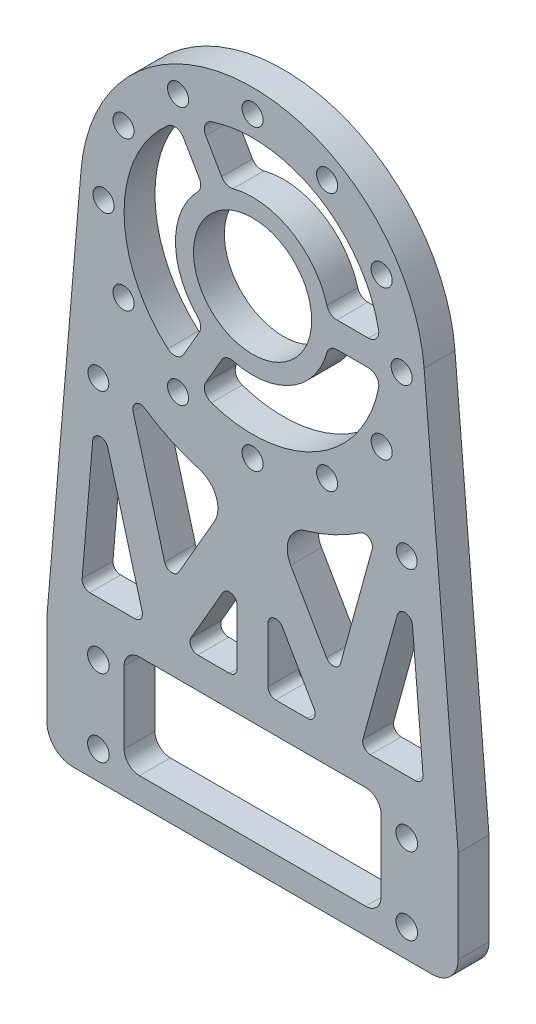
from build123d import *

# Parameters (mm, degrees)
SKETCH_1_R          = 33.5
SKETCH_1_R_2        = 25
SKETCH_1_W          = 80
SKETCH_1_H          = 20
SKETCH_1_R_3        = 2.1
EXTRUDE_1_DEPTH     = 6
SKETCH_3_R          = 2.05
CUT_EXTRUDE_1_DEPTH = 7
EXTRUDE_2_DEPTH     = 6
FILLET_1_R          = 2
SKETCH_5_W          = 80
SKETCH_5_H          = 3
EXTRUDE_3_DEPTH     = 6
FILLET_2_R          = 5
SKETCH_6_W          = 50
SKETCH_6_H          = 20
CUT_EXTRUDE_2_DEPTH = 10
FILLET_3_R          = 3
FILLET_4_R          = 1.5
FILLET_5_R          = 5
SKETCH_7_R          = 2.025
CUT_EXTRUDE_3_DEPTH = 10


with BuildPart() as part:
    # 草图1 → 凸台-拉伸1 (new body)
    with BuildSketch(Plane.XY):
        with Locations((0, 85.5)):
            Circle(SKETCH_1_R)
        with Locations((0, 85.5)):
            Circle(SKETCH_1_R_2, mode=Mode.SUBTRACT)
        with BuildLine():
            Line((-33.38100662, 88.32106311), (-40, 10))
            Line((-40, 10), (40, 10))
            Line((40, 10), (33.38100662, 88.32106311))
            ThreePointArc((33.38100662, 88.32106311), (33.470238435, 86.911785792), (33.5, 85.5))
            ThreePointArc((33.5, 85.5), (-1.411785792, 52.029761565), (-33.38100662, 88.32106311))
        make_face()
        Rectangle(SKETCH_1_W, SKETCH_1_H)
        with Locations((-30, 7.5)):
            Circle(SKETCH_1_R_3, mode=Mode.SUBTRACT)
        with Locations((30, 7.5)):
            Circle(SKETCH_1_R_3, mode=Mode.SUBTRACT)
        with Locations((30, -7.5)):
            Circle(SKETCH_1_R_3, mode=Mode.SUBTRACT)
        with Locations((-30, -7.5)):
            Circle(SKETCH_1_R_3, mode=Mode.SUBTRACT)
    extrude(amount=EXTRUDE_1_DEPTH)

    # 草图3 → 切除-拉伸1 (cut, through all)
    with BuildSketch(Plane.XY.offset(6)):
        with Locations((0, 114.5)):
            Circle(SKETCH_3_R)
        with Locations((14.5, 110.61473671)):
            Circle(SKETCH_3_R)
        with Locations((25.11473671, 100)):
            Circle(SKETCH_3_R)
        with Locations((29, 85.5)):
            Circle(SKETCH_3_R)
        with Locations((25.11473671, 71)):
            Circle(SKETCH_3_R)
        with Locations((14.5, 60.38526329)):
            Circle(SKETCH_3_R)
        with Locations((0, 56.5)):
            Circle(SKETCH_3_R)
        with Locations((-14.5, 60.38526329)):
            Circle(SKETCH_3_R)
        with Locations((-25.11473671, 71)):
            Circle(SKETCH_3_R)
        with Locations((-29, 85.5)):
            Circle(SKETCH_3_R)
        with Locations((-25.11473671, 100)):
            Circle(SKETCH_3_R)
        with Locations((-14.5, 110.61473671)):
            Circle(SKETCH_3_R)
    extrude(amount=-CUT_EXTRUDE_1_DEPTH, mode=Mode.SUBTRACT)


with BuildPart() as body_2:
    # 草图4 → 凸台-拉伸2 (new body)
    with BuildSketch(Plane.XY.offset(6)):
        with BuildLine():
            ThreePointArc((-10.272279454, 108.292109925), (-12.5, 107.150635095), (-14.602406473, 105.792109925))
            Line((-14.602406473, 105.792109925), (-9.560163238, 97.058688457))
            Line((-9.560163238, 97.058688457), (-7.77754959, 93.971111048))
            ThreePointArc((-7.77754959, 93.971111048), (-5.75, 95.459292144), (-3.447422571, 96.471111048))
            Line((-3.447422571, 96.471111048), (-5.230036219, 99.558688457))
            Line((-5.230036219, 99.558688457), (-10.272279454, 108.292109925))
        make_face()
        with BuildLine():
            ThreePointArc((25, 85.5), (24.968651828, 86.751569376), (24.874685928, 88))
            Line((24.874685928, 88), (14.790199458, 88))
            Line((14.790199458, 88), (11.22497216, 88))
            ThreePointArc((11.22497216, 88), (11.431036258, 86.757541283), (11.5, 85.5))
            ThreePointArc((11.5, 85.5), (11.431036258, 84.242458717), (11.22497216, 83))
            Line((11.22497216, 83), (14.790199458, 83))
            Line((14.790199458, 83), (24.874685928, 83))
            ThreePointArc((24.874685928, 83), (24.968651828, 84.248430624), (25, 85.5))
        make_face()
        with BuildLine():
            Line((-9.560163238, 73.941311543), (-14.602406473, 65.207890075))
            ThreePointArc((-14.602406473, 65.207890075), (-12.5, 63.849364905), (-10.272279454, 62.707890075))
            Line((-10.272279454, 62.707890075), (-5.230036219, 71.441311543))
            Line((-5.230036219, 71.441311543), (-3.447422571, 74.528888952))
            ThreePointArc((-3.447422571, 74.528888952), (-5.75, 75.540707856), (-7.77754959, 77.028888952))
            Line((-7.77754959, 77.028888952), (-9.560163238, 73.941311543))
        make_face()
        with BuildLine():
            Line((-7.77754959, 93.971111048), (-9.560163238, 97.058688457))
            ThreePointArc((-9.560163238, 97.058688457), (-15, 85.5), (-9.560163238, 73.941311543))
            Line((-9.560163238, 73.941311543), (-7.77754959, 77.028888952))
            ThreePointArc((-7.77754959, 77.028888952), (-11.5, 85.5), (-7.77754959, 93.971111048))
        make_face()
        with BuildLine():
            Line((-3.447422571, 74.528888952), (-5.230036219, 71.441311543))
            ThreePointArc((-5.230036219, 71.441311543), (7.5, 72.509618943), (14.790199458, 83))
            Line((14.790199458, 83), (11.22497216, 83))
            ThreePointArc((11.22497216, 83), (5.75, 75.540707856), (-3.447422571, 74.528888952))
        make_face()
        with BuildLine():
            ThreePointArc((14.790199458, 88), (7.5, 98.490381057), (-5.230036219, 99.558688457))
            Line((-5.230036219, 99.558688457), (-3.447422571, 96.471111048))
            ThreePointArc((-3.447422571, 96.471111048), (5.75, 95.459292144), (11.22497216, 88))
            Line((11.22497216, 88), (14.790199458, 88))
        make_face()
    extrude(amount=-EXTRUDE_2_DEPTH)

    # Combine 1: union part
    add(part.part)

    # 圆角1
    fillet_1_edges = [body_2.edges().sort_by_distance(p)[0] for p in [
        (-9.560163238, 73.941311543, 3),
        (-14.602406473, 65.207890075, 3),
        (-10.272279454, 62.707890075, 3),
        (-5.230036219, 71.441311543, 3),
        (14.790199458, 83, 3),
        (24.874685928, 83, 3),
        (24.874685928, 88, 3),
        (14.790199458, 88, 3),
        (-5.230036219, 99.558688457, 3),
        (-10.272279454, 108.292109925, 3),
        (-14.602406473, 105.792109925, 3),
        (-9.560163238, 97.058688457, 3),
    ]]
    fillet(fillet_1_edges, radius=FILLET_1_R)

    # 草图5 → 凸台-拉伸3 (add)
    with BuildSketch(Plane.XY.offset(6)):
        with Locations((0, -11.5)):
            Rectangle(SKETCH_5_W, SKETCH_5_H)
    extrude(amount=-EXTRUDE_3_DEPTH)

    # 圆角2
    fillet_2_edges = [body_2.edges().sort_by_distance(p)[0] for p in [
        (-40, -13, 3),
        (40, -13, 3),
    ]]
    fillet(fillet_2_edges, radius=FILLET_2_R)

    # 草图6 → 切除-拉伸2 (cut)
    with BuildSketch(Plane(origin=(0, 0, 0), x_dir=(-1, 0, 0), z_dir=(0, 0, -1))):
        Polygon((-13.279056191, 18), (-3, 18), (-3, 35.803847577), align=None)
        Polygon((3, 35.803847577), (3, 18), (13.279056191, 18), align=None)
        with Locations((0, 2)):
            Rectangle(SKETCH_6_W, SKETCH_6_H)
        Polygon((-33.302523575, 18), (-20.950767875, 18), (-30.401818232, 52.323395297), align=None)
        with BuildLine():
            Line((-16.167580049, 26.996929919), (-3.922674029, 48.205729281))
            ThreePointArc((-3.922674029, 48.205729281), (-14.860033774, 51.069934705), (-24.446601804, 57.063866996))
            Line((-24.446601804, 57.063866996), (-16.167580049, 26.996929919))
        make_face()
        with BuildLine():
            ThreePointArc((24.446601804, 57.063866996), (14.860033774, 51.069934705), (3.922674029, 48.205729281))
            Line((3.922674029, 48.205729281), (16.167580049, 26.996929919))
            Line((16.167580049, 26.996929919), (24.446601804, 57.063866996))
        make_face()
        Polygon((30.401818232, 52.323395297), (20.950767875, 18), (33.302523575, 18), align=None)
    extrude(amount=-CUT_EXTRUDE_2_DEPTH, mode=Mode.SUBTRACT)

    # 圆角3
    fillet_3_edges = [body_2.edges().sort_by_distance(p)[0] for p in [
        (-25, 12, 3),
        (-25, -8, 3),
        (25, -8, 3),
        (25, 12, 3),
    ]]
    fillet(fillet_3_edges, radius=FILLET_3_R)

    # 圆角4
    fillet_4_edges = [body_2.edges().sort_by_distance(p)[0] for p in [
        (-3, 35.803847577, 3),
        (-13.279056191, 18, 3),
        (-3, 18, 3),
        (3, 35.803847577, 3),
        (3, 18, 3),
        (13.279056191, 18, 3),
        (-24.446601804, 57.063866996, 3),
        (-16.167580049, 26.996929919, 3),
        (-20.950767875, 18, 3),
        (-30.401818232, 52.323395297, 3),
        (-33.302523575, 18, 3),
        (20.950767875, 18, 3),
        (33.302523575, 18, 3),
        (30.401818232, 52.323395297, 3),
        (24.446601804, 57.063866996, 3),
        (16.167580049, 26.996929919, 3),
    ]]
    fillet(fillet_4_edges, radius=FILLET_4_R)

    # 圆角5
    fillet_5_edges = [body_2.edges().sort_by_distance(p)[0] for p in [
        (-3.922674029, 48.205729281, 3),
        (3.922674029, 48.205729281, 3),
    ]]
    fillet(fillet_5_edges, radius=FILLET_5_R)

    # 草图7 → 切除-拉伸3 (cut)
    with BuildSketch(Plane(origin=(0, 0, 0), x_dir=(-1, 0, 0), z_dir=(0, 0, -1))):
        with Locations((-30, 55)):
            Circle(SKETCH_7_R)
        with Locations((30, 55)):
            Circle(SKETCH_7_R)
    extrude(amount=-CUT_EXTRUDE_3_DEPTH, mode=Mode.SUBTRACT)


solid = body_2.part
